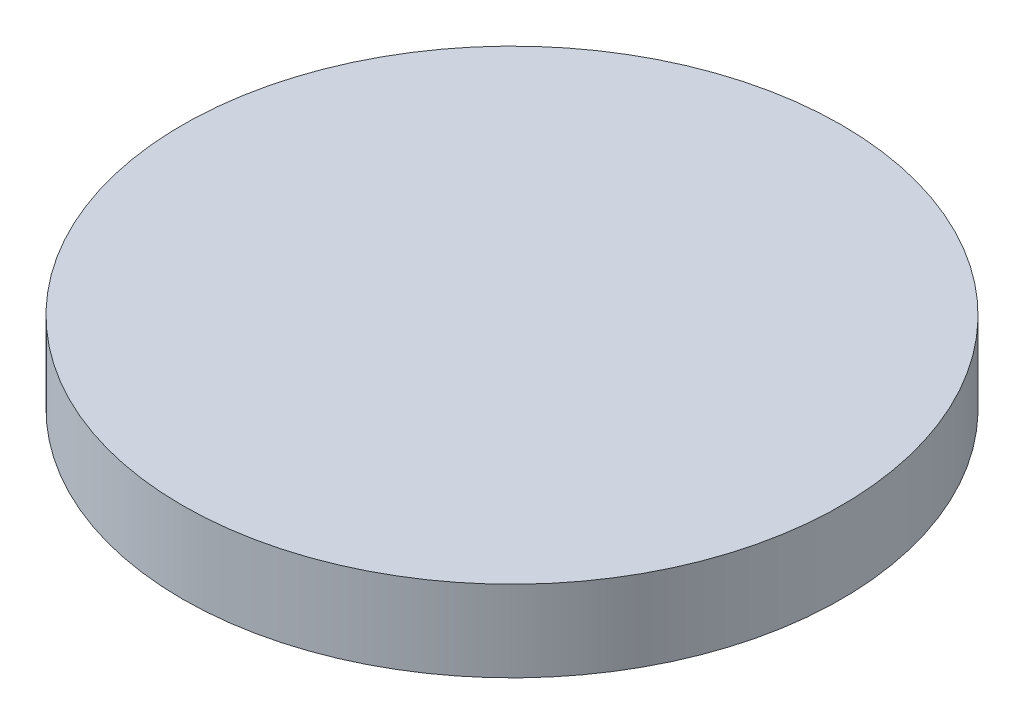
from build123d import *

# Parameters (mm, degrees)
SKETCH1_R           = 101.6
BOSS_EXTRUDE1_DEPTH = 25


with BuildPart() as part:
    # Sketch1 → Boss-Extrude1 (new body)
    with BuildSketch(Plane(origin=(0, 0, 0), x_dir=(1, 0, 0), z_dir=(0, 1, 0))):
        with Locations(Location((0, 0, 0), (0, 0, 270))):
            Circle(SKETCH1_R)
    extrude(amount=BOSS_EXTRUDE1_DEPTH)


solid = part.part
